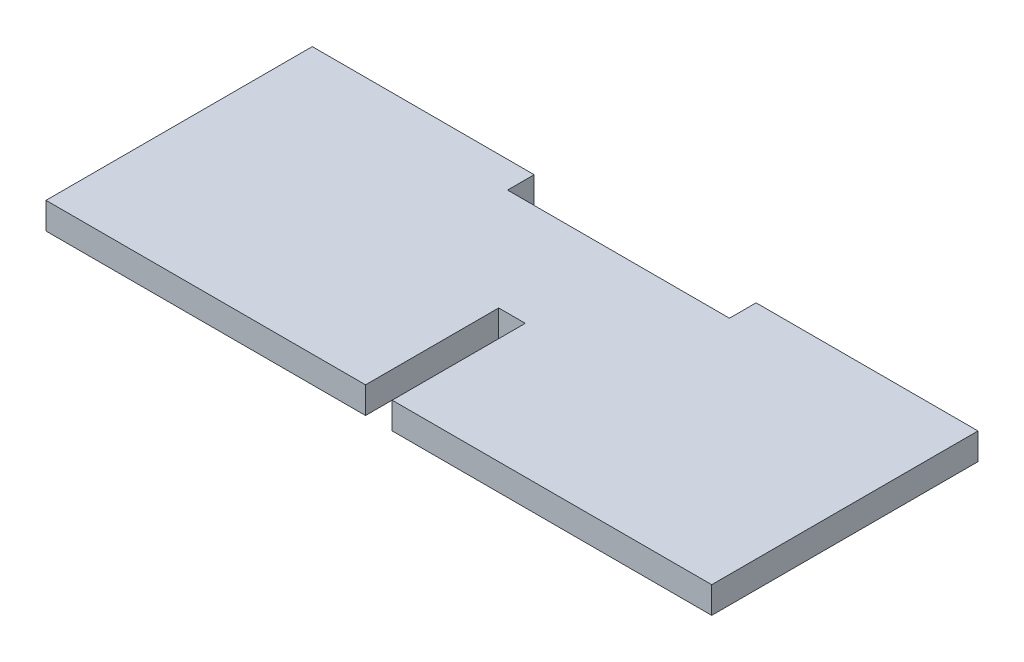
from build123d import *

# Parameters (mm, degrees)
RESSALTO_EXTRUS_O1_DEPTH = 3
ESBO_O2_W                = 25
ESBO_O2_H                = 12.767391237
CORTE_EXTRUS_O1_DEPTH    = 3


with BuildPart() as part:
    # Esboço1 → Ressalto-extrusão1 (new body)
    with BuildSketch(Plane(origin=(0, 0, 0), x_dir=(1, 0, 0), z_dir=(0, 1, 0))):
        Polygon((36, 7.331730769), (-39, 7.331730769), (-39, -22.668269231), (-3, -22.668269231), (-3, -7.668269231), (0, -7.668269231), (0, -22.668269231), (36, -22.668269231), align=None)
    extrude(amount=RESSALTO_EXTRUS_O1_DEPTH)

    # Esboço2 → Corte-extrusão1 (cut)
    with BuildSketch(Plane(origin=(0, 0, -7.331730769), x_dir=(-1, 0, 0), z_dir=(0, 0, -1))):
        with Locations((1.5, 0.308837842)):
            Rectangle(ESBO_O2_W, ESBO_O2_H)
    extrude(amount=-CORTE_EXTRUS_O1_DEPTH, mode=Mode.SUBTRACT)


solid = part.part
